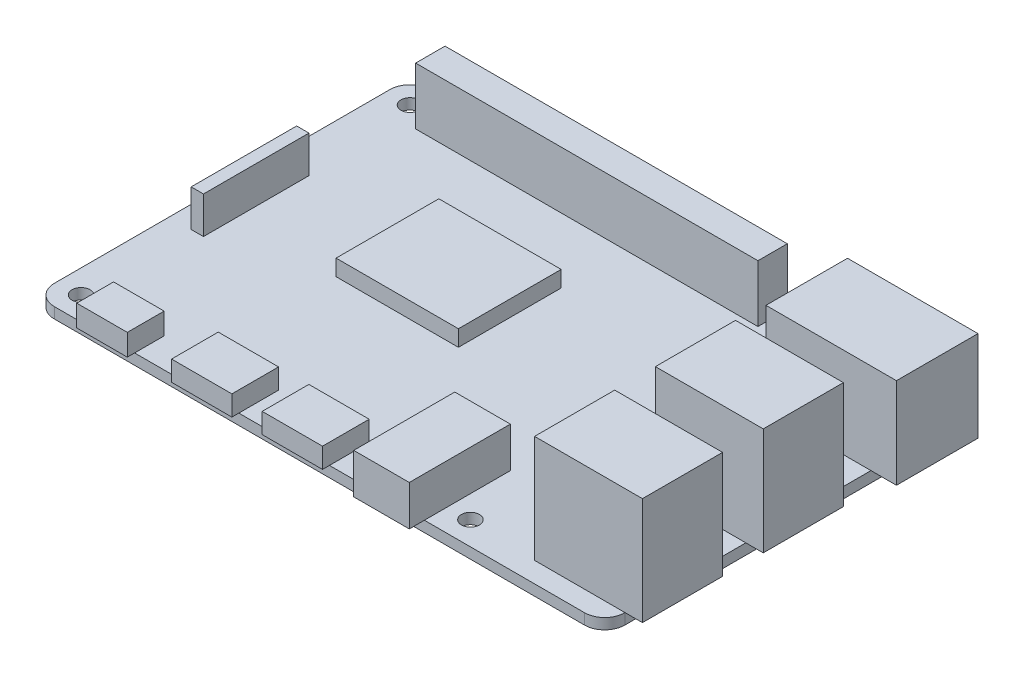
from build123d import *

# Parameters (mm, degrees)
SKETCH1_R           = 1.35
BOSS_EXTRUDE1_DEPTH = 1.6
SKETCH2_W           = 7.53328877
SKETCH2_H           = 5.48663035
BOSS_EXTRUDE2_DEPTH = 3.2
SKETCH3_W           = 8.985946342
SKETCH3_H           = 6.956967826
BOSS_EXTRUDE3_DEPTH = 3
SKETCH4_W           = 8.28060663
SKETCH4_H           = 15.055648418
BOSS_EXTRUDE4_DEPTH = 6
SKETCH5_W           = 16.070010529
SKETCH5_H           = 11.93886501
BOSS_EXTRUDE5_DEPTH = 16
SKETCH6_W           = 19.440745211
SKETCH6_H           = 12.150465756
BOSS_EXTRUDE6_DEPTH = 13.5
SKETCH7_W           = 18.225698636
SKETCH7_H           = 15.309586854
BOSS_EXTRUDE7_DEPTH = 2.4
SKETCH8_W           = 50.998692198
SKETCH8_H           = 4.375780892
BOSS_EXTRUDE8_DEPTH = 8.5
SKETCH9_W           = 1.831399212
SKETCH9_H           = 15.719207136
BOSS_EXTRUDE9_DEPTH = 5.5


with BuildPart() as part:
    # Sketch1 → Boss-Extrude1 (new body)
    with BuildSketch(Plane(origin=(0, 0, 0), x_dir=(1, 0, 0), z_dir=(0, 1, 0))):
        with BuildLine():
            Line((-39.5, -28), (39.5, -28))
            ThreePointArc((39.5, -28), (41.621320344, -27.121320344), (42.5, -25))
            Line((42.5, -25), (42.5, 25))
            ThreePointArc((42.5, 25), (41.621320344, 27.121320344), (39.5, 28))
            Line((39.5, 28), (-39.5, 28))
            ThreePointArc((-39.5, 28), (-41.621320344, 27.121320344), (-42.5, 25))
            Line((-42.5, 25), (-42.5, -25))
            ThreePointArc((-42.5, -25), (-41.621320344, -27.121320344), (-39.5, -28))
        make_face()
        with Locations((-39, 24.5)):
            Circle(SKETCH1_R, mode=Mode.SUBTRACT)
        with Locations((19, 24.5)):
            Circle(SKETCH1_R, mode=Mode.SUBTRACT)
        with Locations((19, -24.5)):
            Circle(SKETCH1_R, mode=Mode.SUBTRACT)
        with Locations((-39, -24.5)):
            Circle(SKETCH1_R, mode=Mode.SUBTRACT)
    extrude(amount=BOSS_EXTRUDE1_DEPTH)

    # Sketch2 → Boss-Extrude2 (add)
    with BuildSketch(Plane(origin=(0, 1.6, 0), x_dir=(1, 0, 0), z_dir=(0, 1, 0))):
        with Locations((-31.3, -26.343842904)):
            Rectangle(SKETCH2_W, SKETCH2_H)
    extrude(amount=BOSS_EXTRUDE2_DEPTH)

    # Sketch3 → Boss-Extrude3 (add)
    with BuildSketch(Plane(origin=(0, 1.6, 0), x_dir=(1, 0, 0), z_dir=(0, 1, 0))):
        with Locations((-16.5, -25.555818694)):
            Rectangle(SKETCH3_W, SKETCH3_H)
        with Locations((-3, -25.555818694)):
            Rectangle(SKETCH3_W, SKETCH3_H)
    extrude(amount=BOSS_EXTRUDE3_DEPTH)

    # Sketch4 → Boss-Extrude4 (add)
    with BuildSketch(Plane(origin=(0, 1.6, 0), x_dir=(1, 0, 0), z_dir=(0, 1, 0))):
        with Locations((11.5, -22.720760552)):
            Rectangle(SKETCH4_W, SKETCH4_H)
    extrude(amount=BOSS_EXTRUDE4_DEPTH)

    # Sketch5 → Boss-Extrude5 (add)
    with BuildSketch(Plane(origin=(0, 1.6, 0), x_dir=(1, 0, 0), z_dir=(0, 1, 0))):
        with Locations((37.060775688, -19)):
            Rectangle(SKETCH5_W, SKETCH5_H)
        with Locations((37.060775688, -1)):
            Rectangle(SKETCH5_W, SKETCH5_H)
    extrude(amount=BOSS_EXTRUDE5_DEPTH)

    # Sketch6 → Boss-Extrude6 (add)
    with BuildSketch(Plane(origin=(0, 1.6, 0), x_dir=(1, 0, 0), z_dir=(0, 1, 0))):
        with Locations((36.574757039, 17.75)):
            Rectangle(SKETCH6_W, SKETCH6_H)
    extrude(amount=BOSS_EXTRUDE6_DEPTH)

    # Sketch7 → Boss-Extrude7 (add)
    with BuildSketch(Plane(origin=(0, 1.6, 0), x_dir=(1, 0, 0), z_dir=(0, 1, 0))):
        with Locations((-13.25, 4.5)):
            Rectangle(SKETCH7_W, SKETCH7_H)
    extrude(amount=BOSS_EXTRUDE7_DEPTH)

    # Sketch8 → Boss-Extrude8 (add)
    with BuildSketch(Plane(origin=(0, 1.6, 0), x_dir=(1, 0, 0), z_dir=(0, 1, 0))):
        with Locations((-10, 24.024952291)):
            Rectangle(SKETCH8_W, SKETCH8_H)
    extrude(amount=BOSS_EXTRUDE8_DEPTH)

    # Sketch9 → Boss-Extrude9 (add)
    with BuildSketch(Plane(origin=(0, 1.6, 0), x_dir=(1, 0, 0), z_dir=(0, 1, 0))):
        with Locations((-38.332266869, 0)):
            Rectangle(SKETCH9_W, SKETCH9_H)
    extrude(amount=BOSS_EXTRUDE9_DEPTH)


solid = part.part
